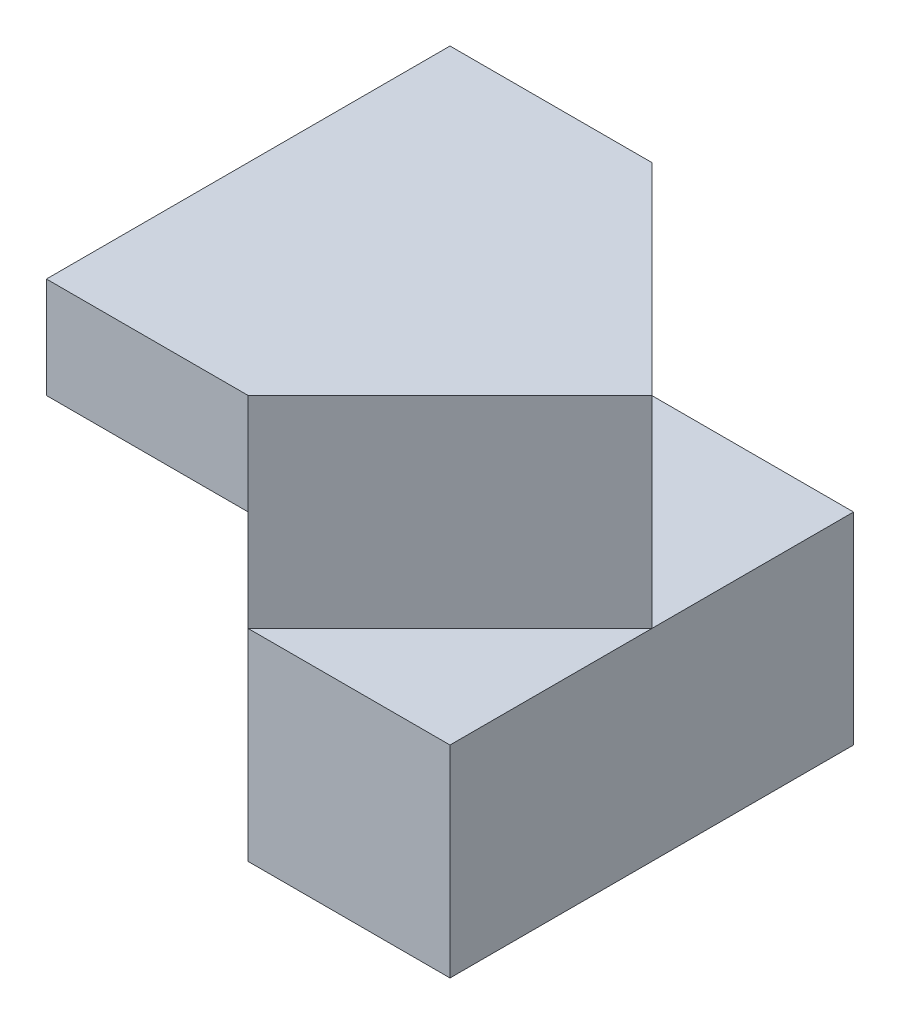
from build123d import *

# Parameters (mm, degrees)
SKETCH5_W           = 4
SKETCH5_H           = 4
BOSS_EXTRUDE2_DEPTH = 4
SKETCH7_W           = 2
SKETCH7_H           = 3
CUT_EXTRUDE5_DEPTH  = 2
CUT_EXTRUDE8_DEPTH  = 2
CUT_EXTRUDE10_DEPTH = 2
CUT_EXTRUDE13_DEPTH = 2


with BuildPart() as part:
    # Sketch5 → Boss-Extrude2 (new body)
    with BuildSketch(Plane(origin=(0, 0, 0), x_dir=(1, 0, 0), z_dir=(0, 1, 0))):
        with Locations((2, 2)):
            Rectangle(SKETCH5_W, SKETCH5_H)
    extrude(amount=BOSS_EXTRUDE2_DEPTH)

    # Sketch7 → Cut-Extrude5 (cut)
    with BuildSketch(Plane.ZY):
        with Locations((-1, 1.5)):
            Rectangle(SKETCH7_W, SKETCH7_H)
    extrude(amount=-CUT_EXTRUDE5_DEPTH, mode=Mode.SUBTRACT)

    # Sketch11 → Cut-Extrude8 (cut)
    with BuildSketch(Plane(origin=(0, 4, 0), x_dir=(1, 0, 0), z_dir=(0, 1, 0))):
        Polygon((2, 0), (4, 2), (4, 0), align=None)
    extrude(amount=-CUT_EXTRUDE8_DEPTH, mode=Mode.SUBTRACT)

    # Sketch13 → Cut-Extrude10 (cut)
    with BuildSketch(Plane(origin=(0, 4, 0), x_dir=(1, 0, 0), z_dir=(0, 1, 0))):
        Polygon((2, 4), (4, 2), (4, 4), align=None)
    extrude(amount=-CUT_EXTRUDE10_DEPTH, mode=Mode.SUBTRACT)

    # Sketch14 → Cut-Extrude13 (cut)
    with BuildSketch(Plane.ZY):
        Polygon((-2, 3), (-4, 0), (-2, 0), align=None)
    extrude(amount=-CUT_EXTRUDE13_DEPTH, mode=Mode.SUBTRACT)


solid = part.part
